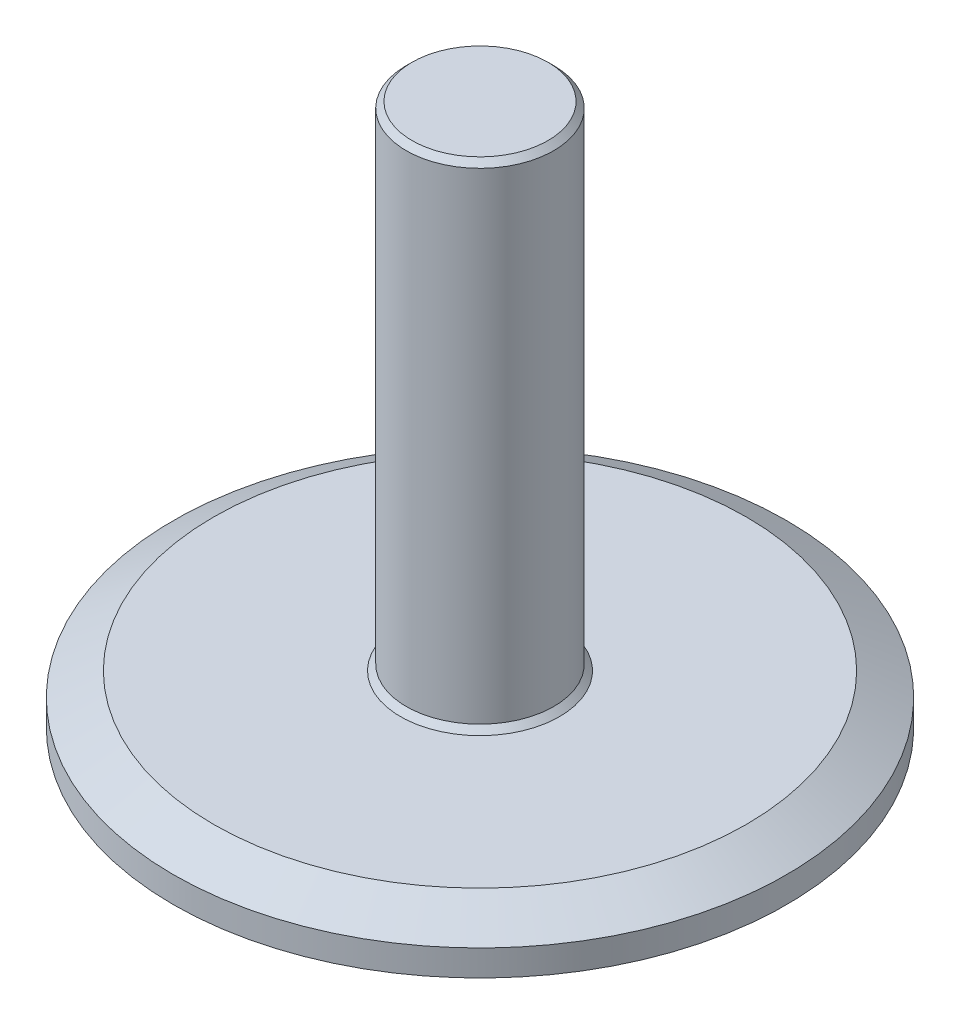
from build123d import *

# Parameters (mm, degrees)
CHAMFER1_SIZE               = 0.75
CHAMFER2_SIZE               = 3
CHAMFER2_SIZE2              = 5.196152423
F_1_4_28_TAPPED_HOLE2_D     = 5.4102
F_1_4_28_TAPPED_HOLE2_DEPTH = 19
F_1_4_28_TAPPED_HOLE2_TIP   = 1.625388061


with BuildPart() as part:
    # Sketch1 → Revolve1 (revolve)
    with BuildSketch(Plane.XY):
        Polygon((0, 0), (0, 70.85), (-9.5, 70.85), (-9.5, 7.35), (-39.5, 7.35), (-39.5, 1), (-32, 1), (-32, 0), align=None)
    revolve(axis=Axis((0, 0, 0), (0, 1, 0)))

    # Chamfer1
    chamfer1_edges = [part.edges().sort_by_distance(p)[0] for p in [
        (9.5, 7.35, 0),
        (9.5, 70.85, 0),
    ]]
    chamfer(chamfer1_edges, length=CHAMFER1_SIZE)

    # Chamfer2
    chamfer2_edges = [part.edges().sort_by_distance(p)[0] for p in [
        (39.5, 7.35, 0),
    ]]
    chamfer2_side = [part.faces().sort_by_distance(p)[0] for p in [
        (39.5, 4.175, 0),
    ]]
    chamfer(chamfer2_edges, length=CHAMFER2_SIZE, length2=CHAMFER2_SIZE2, reference=chamfer2_side[0])

    # 1_4-28 Tapped Hole2
    with Locations(Plane(origin=(0, 0, 0), x_dir=(-1, 0, 0), z_dir=(0, -1, 0))):
        with Locations((86.483740344, -12.823451155), (0, 0)):
            Hole(F_1_4_28_TAPPED_HOLE2_D / 2, depth=F_1_4_28_TAPPED_HOLE2_DEPTH)
            with Locations((0, 0, -(F_1_4_28_TAPPED_HOLE2_DEPTH + F_1_4_28_TAPPED_HOLE2_TIP / 2))):  # 118° drill point
                Cone(0, F_1_4_28_TAPPED_HOLE2_D / 2, F_1_4_28_TAPPED_HOLE2_TIP, mode=Mode.SUBTRACT)


solid = part.part
